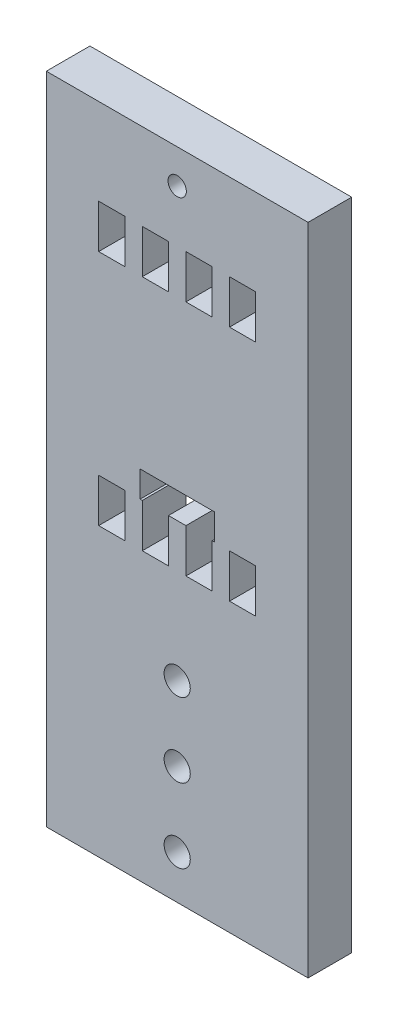
from build123d import *

# Parameters (mm, degrees)
ESQUISSE1_W             = 30
ESQUISSE1_H             = 70
ESQUISSE1_R             = 1.5
ESQUISSE1_W_2           = 3
ESQUISSE1_H_2           = 5
BOSS_EXTRU_1_DEPTH      = 5
ESQUISSE2_W             = 8.5
ESQUISSE2_H             = 3
ENL_V_MAT_EXTRU_1_DEPTH = 5
ESQUISSE3_W             = 30
ESQUISSE3_H             = 5
BOSS_EXTRU_2_DEPTH      = 5
ESQUISSE4_R             = 1.05
ENL_V_MAT_EXTRU_2_DEPTH = 10


with BuildPart() as part:
    # Esquisse1 → Boss.-Extru.1 (new body)
    with BuildSketch(Plane.XY):
        with Locations((15, 35)):
            Rectangle(ESQUISSE1_W, ESQUISSE1_H)
        with Locations((15, 5)):
            Circle(ESQUISSE1_R, mode=Mode.SUBTRACT)
        with Locations((15, 13.5)):
            Circle(ESQUISSE1_R, mode=Mode.SUBTRACT)
        with Locations((15, 22)):
            Circle(ESQUISSE1_R, mode=Mode.SUBTRACT)
        with Locations((12.5, 35.4)):
            Rectangle(ESQUISSE1_W_2, ESQUISSE1_H_2, mode=Mode.SUBTRACT)
        with Locations((7.5, 35.4)):
            Rectangle(ESQUISSE1_W_2, ESQUISSE1_H_2, mode=Mode.SUBTRACT)
        with Locations((17.5, 35.4)):
            Rectangle(ESQUISSE1_W_2, ESQUISSE1_H_2, mode=Mode.SUBTRACT)
        with Locations((22.5, 35.4)):
            Rectangle(ESQUISSE1_W_2, ESQUISSE1_H_2, mode=Mode.SUBTRACT)
        with Locations((22.5, 62.6)):
            Rectangle(ESQUISSE1_W_2, ESQUISSE1_H_2, mode=Mode.SUBTRACT)
        with Locations((17.5, 62.6)):
            Rectangle(ESQUISSE1_W_2, ESQUISSE1_H_2, mode=Mode.SUBTRACT)
        with Locations((12.5, 62.6)):
            Rectangle(ESQUISSE1_W_2, ESQUISSE1_H_2, mode=Mode.SUBTRACT)
        with Locations((7.5, 62.6)):
            Rectangle(ESQUISSE1_W_2, ESQUISSE1_H_2, mode=Mode.SUBTRACT)
    extrude(amount=BOSS_EXTRU_1_DEPTH)

    # Esquisse2 → Enlèv. mat.-Extru.1 (cut)
    with BuildSketch(Plane.XY.offset(5)):
        with Locations((15, 39.4)):
            Rectangle(ESQUISSE2_W, ESQUISSE2_H)
    extrude(amount=-ENL_V_MAT_EXTRU_1_DEPTH, mode=Mode.SUBTRACT)

    # Esquisse3 → Boss.-Extru.2 (add)
    with BuildSketch(Plane(origin=(0, 70, 0), x_dir=(1, 0, 0), z_dir=(0, 1, 0))):
        with Locations((15, -2.5)):
            Rectangle(ESQUISSE3_W, ESQUISSE3_H)
    extrude(amount=BOSS_EXTRU_2_DEPTH)

    # Esquisse4 → Enlèv. mat.-Extru.2 (cut)
    with BuildSketch(Plane.XY.offset(5)):
        with Locations((15, 71.1)):
            Circle(ESQUISSE4_R)
    extrude(amount=-ENL_V_MAT_EXTRU_2_DEPTH, mode=Mode.SUBTRACT)


solid = part.part
